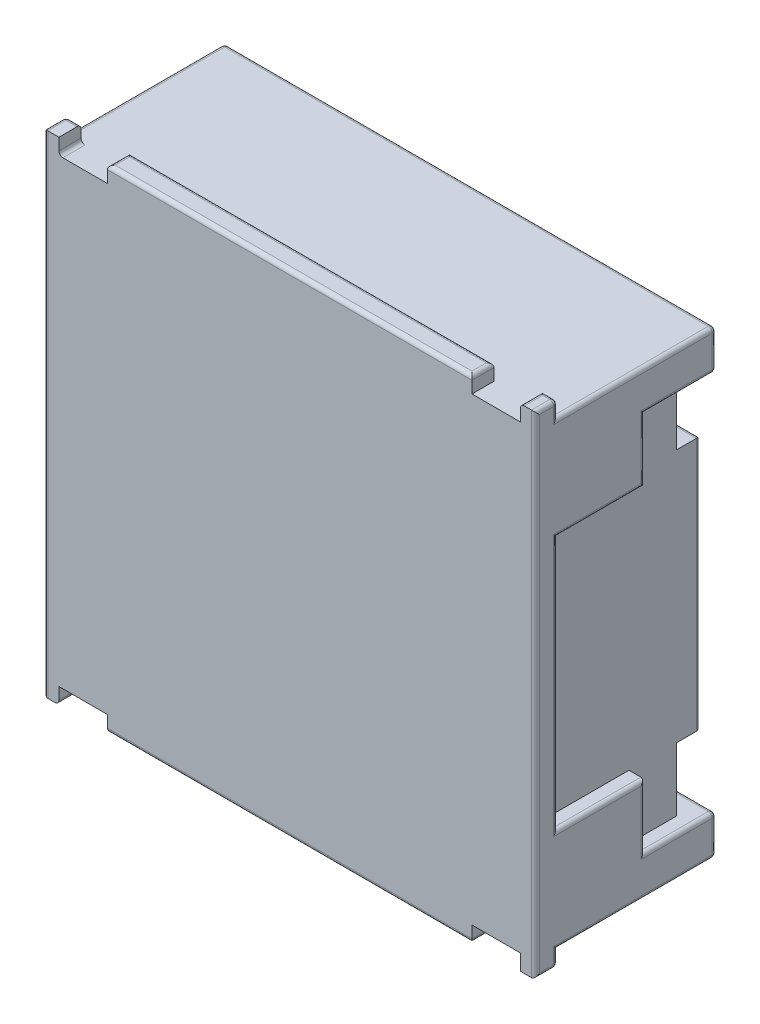
from build123d import *

# Parameters (mm, degrees)
SKETCH1_W           = 6.2
SKETCH1_H           = 6.2
BOSS_EXTRUDE1_DEPTH = 2.38
SKETCH2_W           = 2
SKETCH2_H           = 0.8
CUT_EXTRUDE1_DEPTH  = 0.4
SKETCH3_W           = 6.2
SKETCH3_H           = 0.1
CUT_EXTRUDE2_DEPTH  = 7.2
SKETCH14_W          = 0.2
SKETCH14_H          = 3.2
CUT_EXTRUDE3_DEPTH  = 2
SKETCH16_W          = 2
SKETCH16_H          = 0.2
CUT_EXTRUDE4_DEPTH  = 7.2
SKETCH19_W          = 0.61
SKETCH19_H          = 0.2
CUT_EXTRUDE5_DEPTH  = 1.28
SKETCH20_W          = 0.2
SKETCH20_H          = 0.8
CUT_EXTRUDE6_DEPTH  = 0.6
FILLET1_R           = 0.05


with BuildPart() as part:
    # Sketch1 → Boss-Extrude1 (new body)
    with BuildSketch(Plane.XY):
        Rectangle(SKETCH1_W, SKETCH1_H)
    extrude(amount=BOSS_EXTRUDE1_DEPTH)

    # Sketch2 → Cut-Extrude1 (cut)
    with BuildSketch(Plane(origin=(0, 0, 0), x_dir=(-1, 0, 0), z_dir=(0, 0, -1))):
        with Locations((-2.1, 2)):
            Rectangle(SKETCH2_W, SKETCH2_H)
        with Locations((2.1, 2)):
            Rectangle(SKETCH2_W, SKETCH2_H)
        with Locations((2.1, -2)):
            Rectangle(SKETCH2_W, SKETCH2_H)
        with Locations((-2.1, -2)):
            Rectangle(SKETCH2_W, SKETCH2_H)
    extrude(amount=-CUT_EXTRUDE1_DEPTH, mode=Mode.SUBTRACT)

    # Sketch3 → Cut-Extrude2 (cut, through all)
    with BuildSketch(Plane(origin=(0, 3.1, 0), x_dir=(1, 0, 0), z_dir=(0, 1, 0))):
        with Locations((0, -0.05)):
            Rectangle(SKETCH3_W, SKETCH3_H)
    extrude(amount=-CUT_EXTRUDE2_DEPTH, mode=Mode.SUBTRACT)

    # Sketch14 → Cut-Extrude3 (cut)
    with BuildSketch(Plane(origin=(0, 0, 0.1), x_dir=(-1, 0, 0), z_dir=(0, 0, -1))):
        with Locations((3, 0)):
            Rectangle(SKETCH14_W, SKETCH14_H)
        with Locations((-3, 0)):
            Rectangle(SKETCH14_W, SKETCH14_H)
    extrude(amount=-CUT_EXTRUDE3_DEPTH, mode=Mode.SUBTRACT)

    # Sketch16 → Cut-Extrude4 (cut, through all)
    with BuildSketch(Plane.ZY.offset(3.1)):
        with Locations((1.1, -3)):
            Rectangle(SKETCH16_W, SKETCH16_H)
        with Locations((1.1, 3)):
            Rectangle(SKETCH16_W, SKETCH16_H)
    extrude(amount=-CUT_EXTRUDE4_DEPTH, mode=Mode.SUBTRACT)

    # Sketch19 → Cut-Extrude5 (cut, through all)
    with BuildSketch(Plane(origin=(0, 0, 2.1), x_dir=(-1, 0, 0), z_dir=(0, 0, -1))):
        with Locations((-2.605, -3)):
            Rectangle(SKETCH19_W, SKETCH19_H)
        with Locations((2.605, -3)):
            Rectangle(SKETCH19_W, SKETCH19_H)
        with Locations((2.605, 3)):
            Rectangle(SKETCH19_W, SKETCH19_H)
        with Locations((-2.605, 3)):
            Rectangle(SKETCH19_W, SKETCH19_H)
    extrude(amount=-CUT_EXTRUDE5_DEPTH, mode=Mode.SUBTRACT)

    # Sketch20 → Cut-Extrude6 (cut)
    with BuildSketch(Plane(origin=(0, 0, 0.4), x_dir=(-1, 0, 0), z_dir=(0, 0, -1))):
        with Locations((-3, -2)):
            Rectangle(SKETCH20_W, SKETCH20_H)
        with Locations((-3, 2)):
            Rectangle(SKETCH20_W, SKETCH20_H)
        with Locations((3, 2)):
            Rectangle(SKETCH20_W, SKETCH20_H)
        with Locations((3, -2)):
            Rectangle(SKETCH20_W, SKETCH20_H)
    extrude(amount=-CUT_EXTRUDE6_DEPTH, mode=Mode.SUBTRACT)

    # Fillet1
    fillet1_edges = [part.edges().sort_by_distance(p)[0] for p in [
        (2.3, -3.1, 2.24),
        (0, -3.1, 2.1),
        (-2.3, -3.1, 2.24),
        (0, -3.1, 2.38),
        (-2.3, 3.1, 2.24),
        (0, 3.1, 2.1),
        (2.3, 3.1, 2.24),
        (0, 3.1, 2.38),
        (-3.1, -1.6, 1.55),
        (-3.1, 0, 2.1),
        (-3.1, 1.6, 1.55),
        (-3.1, 2, 1),
        (-3.1, 2.4, 0.55),
        (-3.1, 2.9, 1.1),
        (-3.1, 3, 2.1),
        (-3.1, 3.1, 2.24),
        (-3.1, 0, 2.38),
        (-3.1, -3.1, 2.24),
        (-3.1, -3, 2.1),
        (-3.1, -2.9, 1.1),
        (-3.1, -2.4, 0.55),
        (-3.1, -2, 1),
        (-2.1, 2.4, 0.1),
        (-1.1, 2, 0.1),
        (-2, 1.6, 0.1),
        (-2.9, 0, 0.1),
        (-2, -1.6, 0.1),
        (-1.1, -2, 0.1),
        (-2.1, -2.4, 0.1),
        (-3.1, -2.65, 0.1),
        (0, -2.9, 0.1),
        (2.1, -2.4, 0.1),
        (1.1, -2, 0.1),
        (2, -1.6, 0.1),
        (2.9, 0, 0.1),
        (2, 1.6, 0.1),
        (1.1, 2, 0.1),
        (2.1, 2.4, 0.1),
        (0, 2.9, 0.1),
        (-3.1, 2.65, 0.1),
        (3.1, 1.6, 1.55),
        (3.1, 0, 2.1),
        (3.1, -1.6, 1.55),
        (3.1, -2, 1),
        (3.1, -2.4, 0.55),
        (3.1, -2.65, 0.1),
        (3.1, -2.9, 1.1),
        (3.1, -3, 2.1),
        (3.1, -3.1, 2.24),
        (3.1, 0, 2.38),
        (3.1, 3.1, 2.24),
        (3.1, 3, 2.1),
        (3.1, 2.9, 1.1),
        (3.1, 2.65, 0.1),
        (3.1, 2.4, 0.55),
        (3.1, 2, 1),
        (3.005, -3.1, 2.1),
        (-2.91, -3.1, 2.24),
        (-2.91, -3, 2.1),
        (3.005, 3.1, 2.1),
        (2.91, 3.1, 2.24),
        (-3.005, 3.1, 2.1),
        (-2.91, 2.9, 2.24),
    ]]
    fillet(fillet1_edges, radius=FILLET1_R)


solid = part.part
